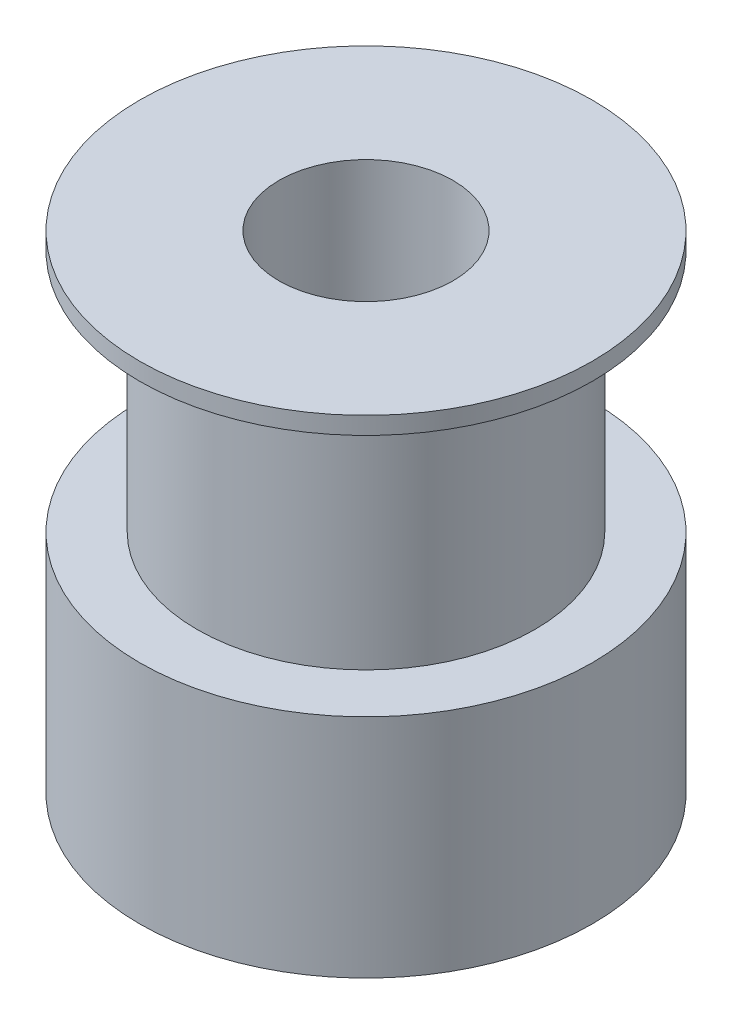
from build123d import *

# Parameters (mm, degrees)
SKETCH_1_R          = 6.5
EXTRUDE_1_DEPTH     = 6.5
SKETCH_2_R          = 4.85
EXTRUDE_2_DEPTH     = 7
SKETCH_3_R          = 6.5
EXTRUDE_3_DEPTH     = 0.5
SKETCH_4_R          = 2.5
CUT_EXTRUDE_1_DEPTH = 15


with BuildPart() as part:
    # 草图1 → 凸台-拉伸1 (new body)
    with BuildSketch(Plane(origin=(0, 0, 0), x_dir=(1, 0, 0), z_dir=(0, 1, 0))):
        Circle(SKETCH_1_R)
    extrude(amount=EXTRUDE_1_DEPTH)

    # 草图2 → 凸台-拉伸2 (add)
    with BuildSketch(Plane(origin=(0, 6.5, 0), x_dir=(1, 0, 0), z_dir=(0, 1, 0))):
        Circle(SKETCH_2_R)
    extrude(amount=EXTRUDE_2_DEPTH)

    # 草图3 → 凸台-拉伸3 (add)
    with BuildSketch(Plane(origin=(0, 13.5, 0), x_dir=(1, 0, 0), z_dir=(0, 1, 0))):
        Circle(SKETCH_3_R)
    extrude(amount=EXTRUDE_3_DEPTH)

    # 草图4 → 切除-拉伸1 (cut, through all)
    with BuildSketch(Plane(origin=(0, 14, 0), x_dir=(1, 0, 0), z_dir=(0, 1, 0))):
        Circle(SKETCH_4_R)
    extrude(amount=-CUT_EXTRUDE_1_DEPTH, mode=Mode.SUBTRACT)


solid = part.part
